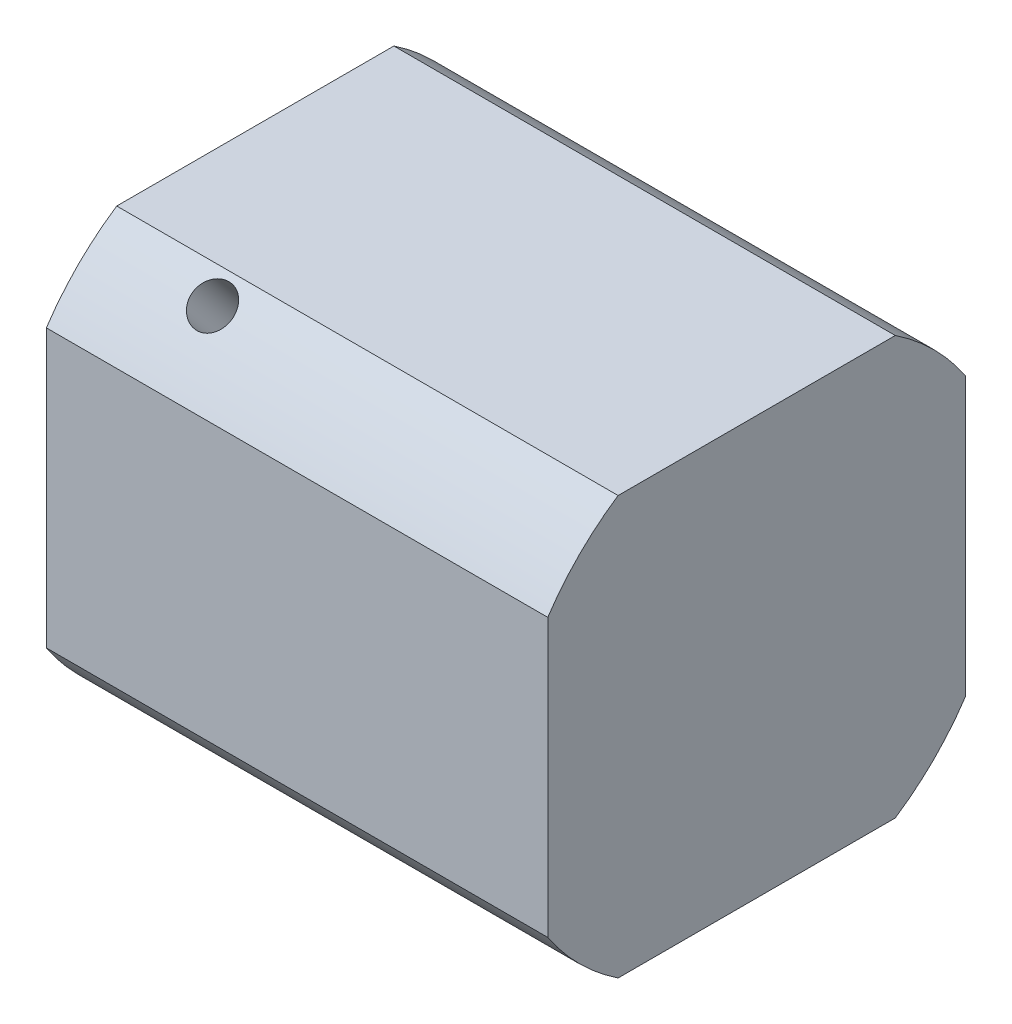
from build123d import *

# Parameters (mm, degrees)
TAP_DRILL_FOR_M3_HELICOIL1_D = 3.15
SKETCH10_W                   = 44.45
SKETCH10_H                   = 44.45
SKETCH10_W_2                 = 31.75
SKETCH10_H_2                 = 31.75
CUT_EXTRUDE2_DEPTH           = 39.1000001
SKETCH11_R                   = 9.525
CUT_EXTRUDE3_DEPTH           = 25.4


with BuildPart() as part:
    # Sketch1 → Revolve1 (revolve)
    with BuildSketch(Plane(origin=(0, 0, 0), x_dir=(1, 0, 0), z_dir=(0, 1, 0))):
        Polygon((0, 0), (0, 19.05), (38.1, 19.05), (38.1, 9.525), (38.1, 0), align=None)
    revolve(axis=Axis((0, 0, 0), (1, 0, 0)))

    # Tap Drill for M3 Helicoil1 (through all)
    with Locations(Plane(origin=(8.941446853, 14.626722755, 12.204977732), x_dir=(0, -0.640681246, 0.767806969), z_dir=(0, 0.767806969, 0.640681246))):
        with Locations((0, 0)):
            Hole(TAP_DRILL_FOR_M3_HELICOIL1_D / 2)

    # Sketch10 → Cut-Extrude2 (cut, through all)
    with BuildSketch(Plane.ZY):
        Rectangle(SKETCH10_W, SKETCH10_H)
        Rectangle(SKETCH10_W_2, SKETCH10_H_2, mode=Mode.SUBTRACT)
    extrude(amount=-CUT_EXTRUDE2_DEPTH, mode=Mode.SUBTRACT)

    # Sketch11 → Cut-Extrude3 (cut)
    with BuildSketch(Plane.ZY):
        Circle(SKETCH11_R)
    extrude(amount=-CUT_EXTRUDE3_DEPTH, mode=Mode.SUBTRACT)


solid = part.part
